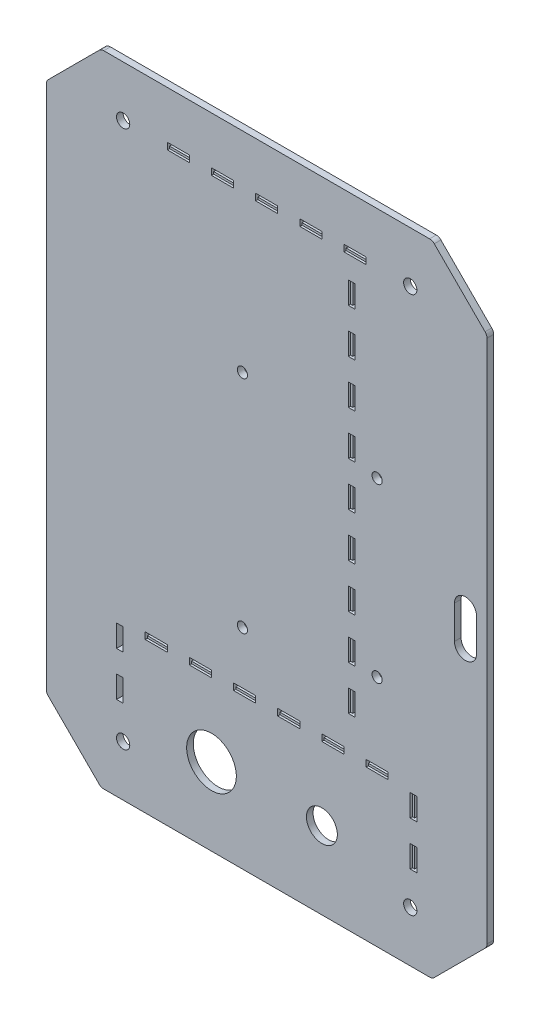
from build123d import *

# Parameters (mm, degrees)
BASE_DEPTH                             = 3
ESQUISSE2_R                            = 3
PER_AGE_PROFIL_DEPTH                   = 5
ESQUISSE3_R                            = 2.3
PER_AGE_LIDAR_DEPTH                    = 4
ESQUISSE4_R                            = 11.25
PER_AGE_BOUTON_D_ARRET_D_URGENCE_DEPTH = 4
ESQUISSE5_R                            = 7
PER_AGE_TIRETTE_DEPTH                  = 4
PER_AGE_CABLE_MANAGEMENT_DEPTH         = 4
SKETCH1_W                              = 10
SKETCH1_H                              = 3
SKETCH1_W_2                            = 3
SKETCH1_H_2                            = 10
CUT_EXTRUDE1_DEPTH                     = 4
CONG_1_R                               = 3
ESQUISSE10_W                           = 90
ESQUISSE10_H                           = 1
ESQUISSE10_W_2                         = 1
ESQUISSE10_H_2                         = 170
ESQUISSE10_W_3                         = 110
ESQUISSE10_H_3                         = 30
BOSS_EXTRU_1_DEPTH                     = 2


with BuildPart() as part:
    # Esquisse1 → Base (new body)
    with BuildSketch(Plane.XY):
        Polygon((-99.748737342, 120), (-75, 144.748737342), (75, 144.748737342), (99.748737342, 120), (99.748737342, -120), (75, -144.748737342), (-75, -144.748737342), (-99.748737342, -120), align=None)
    extrude(amount=BASE_DEPTH)

    # Esquisse2 → Perçage profilé (cut)
    with BuildSketch(Plane.XY.offset(3)):
        with Locations((-65, 121.748737342)):
            Circle(ESQUISSE2_R)
        with Locations((65, 121.748737342)):
            Circle(ESQUISSE2_R)
        with Locations((65, -121.748737342)):
            Circle(ESQUISSE2_R)
        with Locations((-65, -121.748737342)):
            Circle(ESQUISSE2_R)
    extrude(amount=-PER_AGE_PROFIL_DEPTH, mode=Mode.SUBTRACT)

    # Esquisse3 → Perçage Lidar (cut, through all)
    with BuildSketch(Plane(origin=(0, 0, 0), x_dir=(-1, 0, 0), z_dir=(0, 0, -1))):
        with Locations((-50, 39)):
            Circle(ESQUISSE3_R)
        with Locations((11, 50)):
            Circle(ESQUISSE3_R)
        with Locations((-50, -39)):
            Circle(ESQUISSE3_R)
        with Locations((11, -50)):
            Circle(ESQUISSE3_R)
    extrude(amount=-PER_AGE_LIDAR_DEPTH, mode=Mode.SUBTRACT)

    # Esquisse4 → Perçage bouton d'arret d'urgence (cut, through all)
    with BuildSketch(Plane(origin=(0, 0, 0), x_dir=(-1, 0, 0), z_dir=(0, 0, -1))):
        with Locations((25, -109.748737342)):
            Circle(ESQUISSE4_R)
    extrude(amount=-PER_AGE_BOUTON_D_ARRET_D_URGENCE_DEPTH, mode=Mode.SUBTRACT)

    # Esquisse5 → Perçage tirette (cut, through all)
    with BuildSketch(Plane(origin=(0, 0, 0), x_dir=(-1, 0, 0), z_dir=(0, 0, -1))):
        with Locations((-25, -109.748737342)):
            Circle(ESQUISSE5_R)
    extrude(amount=-PER_AGE_TIRETTE_DEPTH, mode=Mode.SUBTRACT)

    # Esquisse7 → Perçage cable management (cut, through all)
    with BuildSketch(Plane(origin=(0, 0, 0), x_dir=(-1, 0, 0), z_dir=(0, 0, -1))):
        with BuildLine():
            Line((-85, 7.5), (-85, -7.5))
            ThreePointArc((-85, -7.5), (-90, -12.5), (-95, -7.5))
            Line((-95, -7.5), (-95, 7.5))
            ThreePointArc((-95, 7.5), (-90, 12.5), (-85, 7.5))
        make_face()
    extrude(amount=-PER_AGE_CABLE_MANAGEMENT_DEPTH, mode=Mode.SUBTRACT)

    # Sketch1 → Cut-Extrude1 (cut, through all)
    with BuildSketch(Plane(origin=(0, 0, 0), x_dir=(-1, 0, 0), z_dir=(0, 0, -1))):
        with Locations((-40, 121.748737342)):
            Rectangle(SKETCH1_W, SKETCH1_H)
        with Locations((-20, 121.748737342)):
            Rectangle(SKETCH1_W, SKETCH1_H)
        with Locations((0, 121.748737342)):
            Rectangle(SKETCH1_W, SKETCH1_H)
        with Locations((20, 121.748737342)):
            Rectangle(SKETCH1_W, SKETCH1_H)
        with Locations((40, 121.748737342)):
            Rectangle(SKETCH1_W, SKETCH1_H)
        with Locations((-66.5, -101.748737342)):
            Rectangle(SKETCH1_W_2, SKETCH1_H_2)
        with Locations((-38.5, 85.248737342)):
            Rectangle(SKETCH1_W_2, SKETCH1_H_2)
        with Locations((-38.5, 105.248737342)):
            Rectangle(SKETCH1_W_2, SKETCH1_H_2)
        with Locations((-66.5, -81.748737342)):
            Rectangle(SKETCH1_W_2, SKETCH1_H_2)
        with Locations((66.5, -81.748737342)):
            Rectangle(SKETCH1_W_2, SKETCH1_H_2)
        with Locations((66.5, -101.748737342)):
            Rectangle(SKETCH1_W_2, SKETCH1_H_2)
        with Locations((-30, -75.248737342)):
            Rectangle(SKETCH1_W, SKETCH1_H)
        with Locations((-50, -75.248737342)):
            Rectangle(SKETCH1_W, SKETCH1_H)
        with Locations((-10, -75.248737342)):
            Rectangle(SKETCH1_W, SKETCH1_H)
        with Locations((10, -75.248737342)):
            Rectangle(SKETCH1_W, SKETCH1_H)
        with Locations((30, -75.248737342)):
            Rectangle(SKETCH1_W, SKETCH1_H)
        with Locations((50, -75.248737342)):
            Rectangle(SKETCH1_W, SKETCH1_H)
        with Locations((-38.5, 65.248737342)):
            Rectangle(SKETCH1_W_2, SKETCH1_H_2)
        with Locations((-38.5, 45.248737342)):
            Rectangle(SKETCH1_W_2, SKETCH1_H_2)
        with Locations((-38.5, 25.248737342)):
            Rectangle(SKETCH1_W_2, SKETCH1_H_2)
        with Locations((-38.5, 5.248737342)):
            Rectangle(SKETCH1_W_2, SKETCH1_H_2)
        with Locations((-38.5, -14.751262658)):
            Rectangle(SKETCH1_W_2, SKETCH1_H_2)
        with Locations((-38.5, -34.751262658)):
            Rectangle(SKETCH1_W_2, SKETCH1_H_2)
        with Locations((-38.5, -54.751262658)):
            Rectangle(SKETCH1_W_2, SKETCH1_H_2)
    extrude(amount=-CUT_EXTRUDE1_DEPTH, mode=Mode.SUBTRACT)

    # Congé1
    cong_1_edges = [part.edges().sort_by_distance(p)[0] for p in [
        (-99.748737342, 120, 1.5),
        (-75, 144.748737342, 1.5),
        (75, 144.748737342, 1.5),
        (99.748737342, 120, 1.5),
        (99.748737342, -120, 1.5),
        (75, -144.748737342, 1.5),
        (-75, -144.748737342, 1.5),
        (-99.748737342, -120, 1.5),
    ]]
    fillet(cong_1_edges, radius=CONG_1_R)

    # Esquisse10 → Boss.-Extru.1 (add)
    with BuildSketch(Plane(origin=(0, 0, 0), x_dir=(-1, 0, 0), z_dir=(0, 0, -1))):
        with Locations((0, 120.748737342)):
            Rectangle(ESQUISSE10_W, ESQUISSE10_H)
        with Locations((-37.5, 25.248737342)):
            Rectangle(ESQUISSE10_W_2, ESQUISSE10_H_2)
        with Locations((0, -76.248737342)):
            Rectangle(ESQUISSE10_W_3, ESQUISSE10_H)
        with Locations((65.5, -91.748737342)):
            Rectangle(ESQUISSE10_W_2, ESQUISSE10_H_3)
        with Locations((-65.5, -91.748737342)):
            Rectangle(ESQUISSE10_W_2, ESQUISSE10_H_3)
    extrude(amount=-BOSS_EXTRU_1_DEPTH)


solid = part.part
